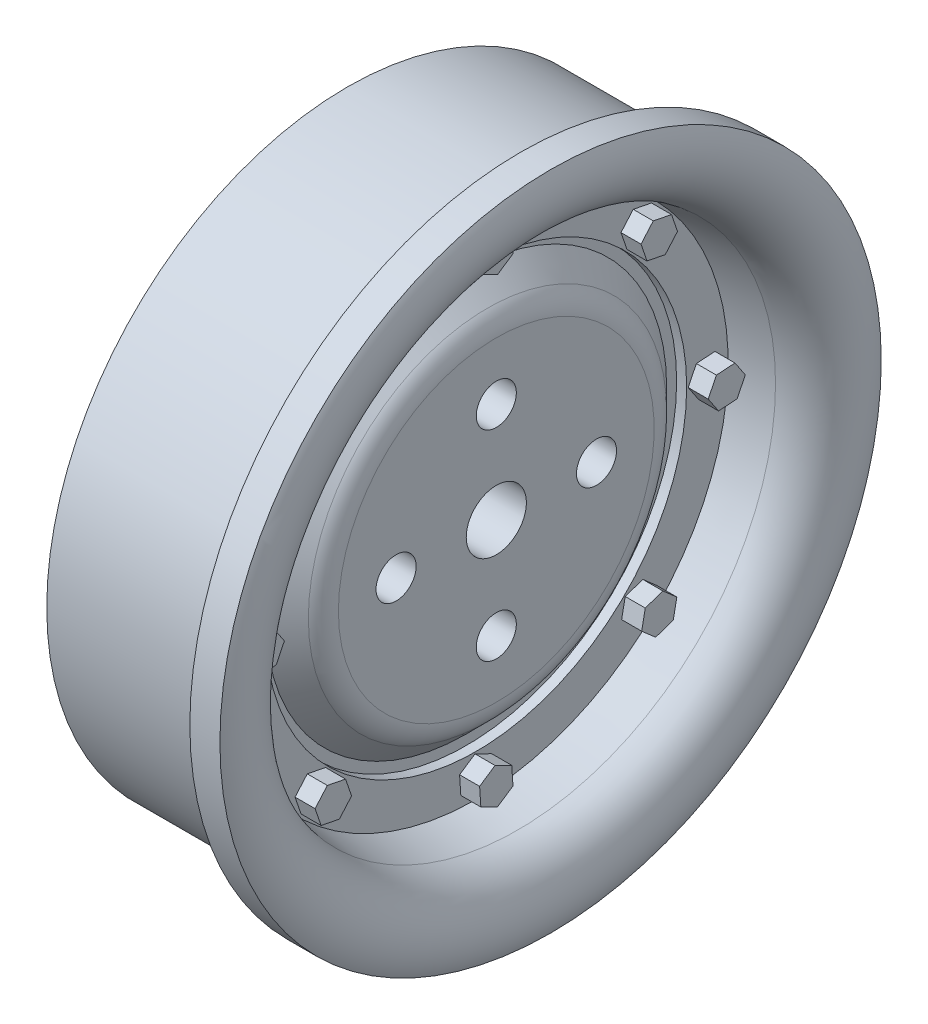
from build123d import *

# Parameters (mm, degrees)
FILLET1_R           = 1.5
SKETCH2_R           = 1
CUT_EXTRUDE1_DEPTH  = 5
BOSS_EXTRUDE1_DEPTH = 1


with BuildPart() as part:
    # Sketch1 → Revolve1 (revolve)
    with BuildSketch(Plane(origin=(0, 0, 0), x_dir=(1, 0, 0), z_dir=(0, 1, 0))):
        with BuildLine():
            Line((0.095371477, 16.5), (-1.404628523, 16.5))
            Line((-1.404628523, 16.5), (-1.404628523, 15))
            Line((-1.404628523, 15), (-10.044628523, 15))
            Line((-10.044628523, 15), (-10.044628523, 13))
            Line((-10.044628523, 13), (-7.631517886, 13))
            Line((-7.631517886, 13), (-7.631517886, 3.5))
            Line((-7.631517886, 3.5), (-10.044628523, 3.5))
            Line((-10.044628523, 3.5), (-10.044628523, 1.5))
            Line((-10.044628523, 1.5), (-7.631517886, 1.5))
            Line((-7.631517886, 1.5), (-2.613091993, 1.5))
            Line((-2.613091993, 1.5), (-2.613091993, 8.5))
            Line((-2.613091993, 8.5), (-4.113091993, 10))
            Line((-4.113091993, 10), (-4.113091993, 10.5))
            Line((-4.113091993, 10.5), (-3.613091993, 10.5))
            Line((-3.613091993, 10.5), (-3.613091993, 12.570770776))
            Line((-3.613091993, 12.570770776), (-1.543093741, 12.863761539))
            ThreePointArc((-1.543093741, 12.863761539), (0.164689844, 14.281505523), (0.095371477, 16.5))
        make_face()
    revolve(axis=Axis((-25, 0, 0), (1, 0, 0)))

    # Fillet1
    fillet1_edges = [part.edges().sort_by_distance(p)[0] for p in [
        (-2.613091993, 0, 8.5),
    ]]
    fillet(fillet1_edges, radius=FILLET1_R)

    # Sketch2 → Cut-Extrude1 (cut, symmetric)
    with BuildSketch(Plane(origin=(-2.613091993, 0, 0), x_dir=(0, 0, -1), z_dir=(1, 0, 0))):
        with Locations((0, 5)):
            Circle(SKETCH2_R)
        with Locations((5, 0)):
            Circle(SKETCH2_R)
        with Locations((0, -5)):
            Circle(SKETCH2_R)
        with Locations((-5, 0)):
            Circle(SKETCH2_R)
    extrude(amount=CUT_EXTRUDE1_DEPTH, both=True, mode=Mode.SUBTRACT)

    # Sketch3 → Boss-Extrude1 (add)
    with BuildSketch(Plane(origin=(-3.613091993, 0, 0), x_dir=(0, 0, -1), z_dir=(1, 0, 0))):
        Polygon((8.43091754, 7.253822764), (9.041610985, 7.95188113), (8.742421428, 8.82978635), (7.832538427, 9.009633204), (7.221844982, 8.311574837), (7.521034539, 7.433669617), align=None)
        Polygon((0.832331699, 11.09078623), (0.77055537, 12.016213511), (-0.061776329, 12.425427281), (-0.832331699, 11.90921377), (-0.77055537, 10.983786489), (0.061776329, 10.574572719), align=None)
        Polygon((11.09078623, -0.832331699), (12.016213511, -0.77055537), (12.425427281, 0.061776329), (11.90921377, 0.832331699), (10.983786489, 0.77055537), (10.574572719, -0.061776329), align=None)
        Polygon((7.253822764, -8.43091754), (7.95188113, -9.041610985), (8.82978635, -8.742421428), (9.009633204, -7.832538427), (8.311574837, -7.221844982), (7.433669617, -7.521034539), align=None)
        Polygon((-0.832331699, -11.09078623), (-0.77055537, -12.016213511), (0.061776329, -12.425427281), (0.832331699, -11.90921377), (0.77055537, -10.983786489), (-0.061776329, -10.574572719), align=None)
        Polygon((-8.43091754, -7.253822764), (-9.041610985, -7.95188113), (-8.742421428, -8.82978635), (-7.832538427, -9.009633204), (-7.221844982, -8.311574837), (-7.521034539, -7.433669617), align=None)
        Polygon((-11.09078623, 0.832331699), (-12.016213511, 0.77055537), (-12.425427281, -0.061776329), (-11.90921377, -0.832331699), (-10.983786489, -0.77055537), (-10.574572719, 0.061776329), align=None)
        Polygon((-7.253822764, 8.43091754), (-7.95188113, 9.041610985), (-8.82978635, 8.742421428), (-9.009633204, 7.832538427), (-8.311574837, 7.221844982), (-7.433669617, 7.521034539), align=None)
    extrude(amount=BOSS_EXTRUDE1_DEPTH)


solid = part.part
